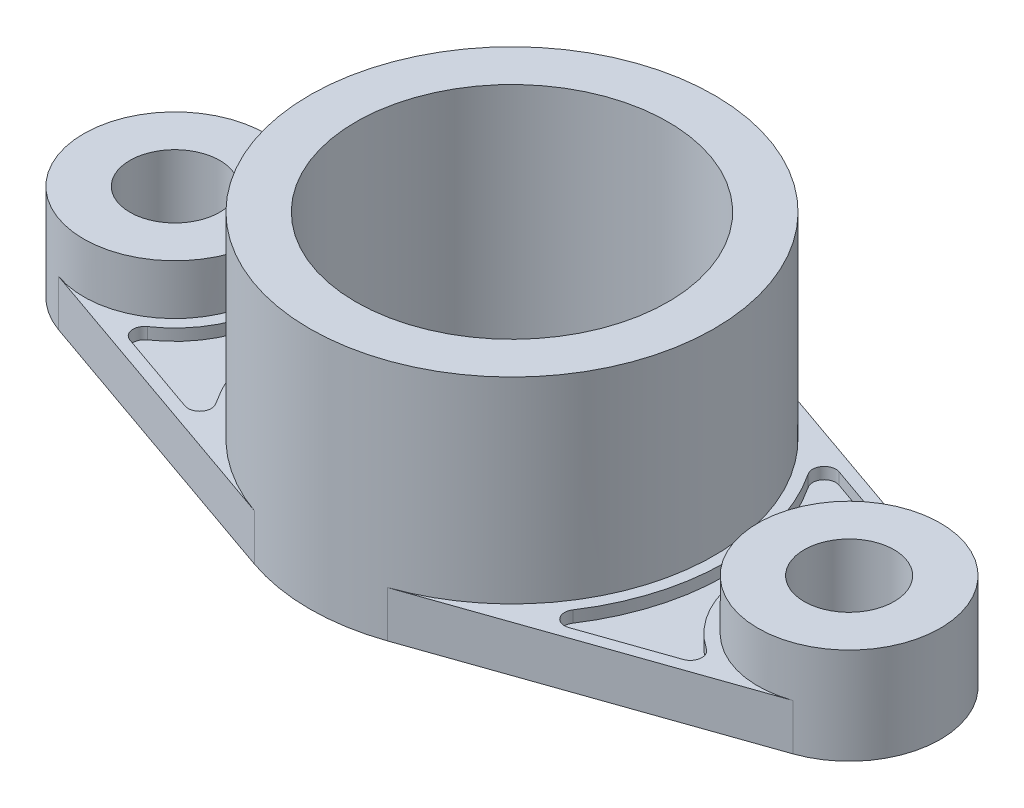
from build123d import *

# Parameters (mm, degrees)
SKETCH1_R           = 40.5
SKETCH1_R_2         = 11.665
BOSS_EXTRUDE1_DEPTH = 12
SKETCH1_3_R         = 23.665
SKETCH1_3_R_2       = 11.665
SKETCH1_3_R_3       = 52.5
SKETCH1_3_R_4       = 40.5
BOSS_EXTRUDE2_DEPTH = 25
SKETCH1_4_R         = 40.5
BOSS_EXTRUDE3_DEPTH = 63
CUT_EXTRUDE1_DEPTH  = 3
FILLET1_R           = 3
FILLET2_R           = 3


with BuildPart() as part:
    # Sketch1 → Boss-Extrude1 (new body)
    with BuildSketch(Plane(origin=(0, 0, 0), x_dir=(1, 0, 0), z_dir=(0, 1, 0))):
        with BuildLine():
            Line((-17.301, 49.56738241), (-95.298631714, 22.343087709))
            ThreePointArc((-95.298631714, 22.343087709), (-111.165, 0), (-95.298631714, -22.343087709))
            Line((-95.298631714, -22.343087709), (-17.301, -49.56738241))
            ThreePointArc((-17.301, -49.56738241), (0, -52.5), (17.301, -49.56738241))
            Line((17.301, -49.56738241), (95.298631714, -22.343087709))
            ThreePointArc((95.298631714, -22.343087709), (111.165, 0), (95.298631714, 22.343087709))
            Line((95.298631714, 22.343087709), (17.301, 49.56738241))
            ThreePointArc((17.301, 49.56738241), (0, 52.5), (-17.301, 49.56738241))
        make_face()
        Circle(SKETCH1_R, mode=Mode.SUBTRACT)
        with Locations((-87.5, 0)):
            Circle(SKETCH1_R_2, mode=Mode.SUBTRACT)
        with Locations((87.5, 0)):
            Circle(SKETCH1_R_2, mode=Mode.SUBTRACT)
    extrude(amount=BOSS_EXTRUDE1_DEPTH)

    # Sketch1_3 → Boss-Extrude2 (add)
    # profile 1 of 3: a face of its own
    with BuildSketch(Plane(origin=(0, 0, 0), x_dir=(1, 0, 0), z_dir=(0, 1, 0))):
        with Locations((-87.5, 0)):
            Circle(SKETCH1_3_R)
        with Locations((-87.5, 0)):
            Circle(SKETCH1_3_R_2, mode=Mode.SUBTRACT)
    # profile 2 of 3: a face of its own
    with BuildSketch(Plane(origin=(0, 0, 0), x_dir=(1, 0, 0), z_dir=(0, 1, 0))):
        Circle(SKETCH1_3_R_3)
        Circle(SKETCH1_3_R_4, mode=Mode.SUBTRACT)
    # profile 3 of 3: a face of its own
    with BuildSketch(Plane(origin=(0, 0, 0), x_dir=(1, 0, 0), z_dir=(0, 1, 0))):
        with Locations((87.5, 0)):
            Circle(SKETCH1_3_R)
        with Locations((87.5, 0)):
            Circle(SKETCH1_3_R_2, mode=Mode.SUBTRACT)
    extrude(amount=BOSS_EXTRUDE2_DEPTH)

    # Sketch1_4 → Boss-Extrude3 (add)
    with BuildSketch(Plane(origin=(0, 0, 0), x_dir=(1, 0, 0), z_dir=(0, 1, 0))):
        with BuildLine():
            ThreePointArc((17.301, 49.56738241), (0, 52.5), (-17.301, 49.56738241))
            ThreePointArc((-17.301, 49.56738241), (-52.5, 0), (-17.301, -49.56738241))
            ThreePointArc((-17.301, -49.56738241), (0, -52.5), (17.301, -49.56738241))
            ThreePointArc((17.301, -49.56738241), (42.805096075, -30.396936523), (52.5, 0))
            ThreePointArc((52.5, 0), (42.805096075, 30.396936523), (17.301, 49.56738241))
        make_face()
        Circle(SKETCH1_4_R, mode=Mode.SUBTRACT)
    extrude(amount=BOSS_EXTRUDE3_DEPTH)

    # Sketch2 → Cut-Extrude1 (cut)
    with BuildSketch(Plane(origin=(0, 12, 0), x_dir=(1, 0, 0), z_dir=(0, 1, 0))):
        with BuildLine():
            Line((-78.3996229, -25.064025248), (-40.010112847, -38.46350049))
            ThreePointArc((-40.010112847, -38.46350049), (-55.5, 0), (-40.010112847, 38.46350049))
            Line((-40.010112847, 38.46350049), (-78.3996229, 25.064025248))
            ThreePointArc((-78.3996229, 25.064025248), (-60.835, 0), (-78.3996229, -25.064025248))
        make_face()
        with BuildLine():
            Line((78.3996229, 25.064025248), (40.010112847, 38.46350049))
            ThreePointArc((40.010112847, 38.46350049), (55.5, 0), (40.010112847, -38.46350049))
            Line((40.010112847, -38.46350049), (78.3996229, -25.064025248))
            ThreePointArc((78.3996229, -25.064025248), (60.835, 0), (78.3996229, 25.064025248))
        make_face()
    extrude(amount=-CUT_EXTRUDE1_DEPTH, mode=Mode.SUBTRACT)

    # Fillet1
    fillet1_edges = [part.edges().sort_by_distance(p)[0] for p in [
        (-78.3996229, 10.5, -25.064025248),
        (-78.3996229, 10.5, 25.064025248),
        (-40.010112847, 10.5, 38.46350049),
        (-40.010112847, 10.5, -38.46350049),
    ]]
    fillet(fillet1_edges, radius=FILLET1_R)

    # Fillet2
    fillet2_edges = [part.edges().sort_by_distance(p)[0] for p in [
        (78.3996229, 10.5, 25.064025248),
        (78.3996229, 10.5, -25.064025248),
        (40.010112847, 10.5, -38.46350049),
        (40.010112847, 10.5, 38.46350049),
    ]]
    fillet(fillet2_edges, radius=FILLET2_R)


solid = part.part
